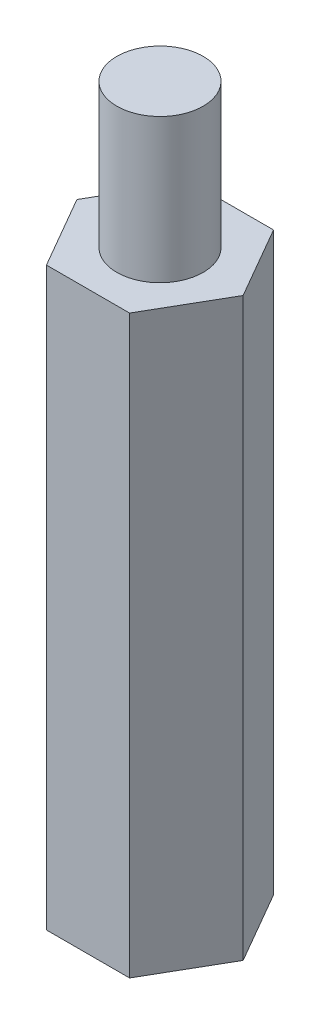
from build123d import *

# Parameters (mm, degrees)
EXTRUDE_1_DEPTH     = 20
SKETCH_2_R          = 1.5
EXTRUDE_2_DEPTH     = 5
SKETCH_3_R          = 1.5
CUT_EXTRUDE_1_DEPTH = 5


with BuildPart() as part:
    # 草圖1 → 填料-伸長1 (new body)
    with BuildSketch(Plane(origin=(0, 0, 0), x_dir=(1, 0, 0), z_dir=(0, 1, 0))):
        Polygon((2.886751346, 0), (1.443375673, 2.5), (-1.443375673, 2.5), (-2.886751346, 0), (-1.443375673, -2.5), (1.443375673, -2.5), align=None)
    extrude(amount=EXTRUDE_1_DEPTH)

    # 草圖2 → 填料-伸長2 (add)
    with BuildSketch(Plane(origin=(0, 20, 0), x_dir=(1, 0, 0), z_dir=(0, 1, 0))):
        Circle(SKETCH_2_R)
    extrude(amount=EXTRUDE_2_DEPTH)

    # 草圖3 → 除料-伸長1 (cut)
    with BuildSketch(Plane.XZ):
        Circle(SKETCH_3_R)
    extrude(amount=-CUT_EXTRUDE_1_DEPTH, mode=Mode.SUBTRACT)


solid = part.part
